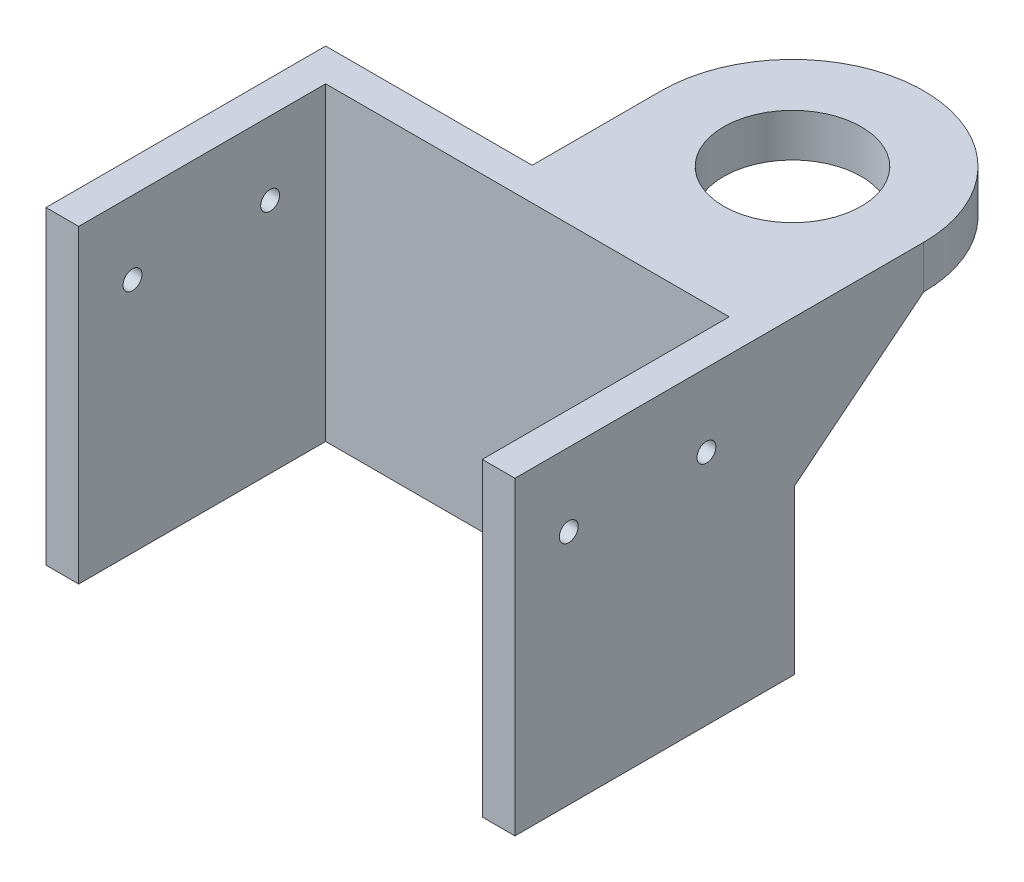
from build123d import *

# Parameters (mm, degrees)
SKETCH_1_W          = 54.5
SKETCH_1_H          = 32.5
EXTRUDE_2_DEPTH     = 34
EXTRUDE_3_DEPTH     = 5
EXTRUDE_6_DEPTH     = 4
SKETCH_14_W         = 46.9
SKETCH_14_H         = 28.7
CUT_EXTRUDE_6_DEPTH = 35
SKETCH_15_R         = 1.1
CUT_EXTRUDE_7_DEPTH = 47
EXTRUDE_7_DEPTH     = 2
SKETCH_18_R         = 8
CUT_EXTRUDE_8_DEPTH = 10
SKETCH_19_R         = 1
CUT_EXTRUDE_9_DEPTH = 20


with BuildPart() as part:
    # 草图1 → 凸台-拉伸2 (new body)
    with BuildSketch(Plane(origin=(0, 0, 0), x_dir=(1, 0, 0), z_dir=(0, 1, 0))):
        with Locations((4.534184514, 3.63509061)):
            Rectangle(SKETCH_1_W, SKETCH_1_H)
    extrude(amount=EXTRUDE_2_DEPTH)

    # 草图3 → 凸台-拉伸3 (add)
    with BuildSketch(Plane(origin=(0, 34, 0), x_dir=(1, 0, 0), z_dir=(0, 1, 0))):
        with BuildLine():
            Line((1.284184514, 34.88509061), (1.284184514, 19.88509061))
            Line((1.284184514, 19.88509061), (31.784184514, 19.88509061))
            Line((31.784184514, 19.88509061), (31.784184514, 34.88509061))
            ThreePointArc((31.784184514, 34.88509061), (16.534184514, 50.13509061), (1.284184514, 34.88509061))
        make_face()
    extrude_3 = extrude(amount=-EXTRUDE_3_DEPTH)

    # 草图11 → 凸台-拉伸6 (add)
    with BuildSketch(Plane.ZY.offset(-1.284184514)):
        Polygon((-34.88509061, 29), (-19.88509061, 17), (-19.88509061, 29), align=None)
    extrude_6 = extrude(amount=-EXTRUDE_6_DEPTH)

    # 镜向1: 凸台-拉伸3, 凸台-拉伸6 across plane
    add(extrude_3.mirror(Plane.ZY.offset(-16.534184514)))
    add(extrude_6.mirror(Plane.ZY.offset(-16.534184514)))

    # 草图14 → 切除-拉伸6 (cut, through all)
    with BuildSketch(Plane(origin=(0, 34, 0), x_dir=(1, 0, 0), z_dir=(0, 1, 0))):
        with Locations((4.534184514, 1.73509061)):
            Rectangle(SKETCH_14_W, SKETCH_14_H)
    extrude(amount=-CUT_EXTRUDE_6_DEPTH, mode=Mode.SUBTRACT)

    # 草图15 → 切除-拉伸7 (cut, symmetric)
    with BuildSketch(Plane.ZY.offset(-16.534184514)):
        with Locations((-9.63509061, 25.5)):
            Circle(SKETCH_15_R)
        with Locations((6.36490939, 25.5)):
            Circle(SKETCH_15_R)
    extrude(amount=CUT_EXTRUDE_7_DEPTH, both=True, mode=Mode.SUBTRACT)

    # 草图17 → 凸台-拉伸7 (add)
    with BuildSketch(Plane(origin=(0, 0, 0), x_dir=(1, 0, 0), z_dir=(0, 1, 0))):
        Polygon((-22.715815486, -12.61490939), (-22.715815486, 19.88509061), (31.784184514, 19.88509061), (31.784184514, -12.61490939), (27.984184514, -12.61490939), (27.984184514, 16.08509061), (-18.915815486, 16.08509061), (-18.915815486, -12.61490939), align=None)
    extrude(amount=-EXTRUDE_7_DEPTH)

    # 草图18 → 切除-拉伸8 (cut)
    with BuildSketch(Plane(origin=(0, 34, 0), x_dir=(1, 0, 0), z_dir=(0, 1, 0))):
        with Locations((16.534184514, 34.88509061)):
            Circle(SKETCH_18_R)
    extrude(amount=-CUT_EXTRUDE_8_DEPTH, mode=Mode.SUBTRACT)

    # 草图19 → 切除-拉伸9 (cut)
    with BuildSketch(Plane.XZ.offset(2)):
        with Locations((29.784184514, -17.88509061)):
            Circle(SKETCH_19_R)
        with Locations((-20.715815486, -17.88509061)):
            Circle(SKETCH_19_R)
    extrude(amount=-CUT_EXTRUDE_9_DEPTH, mode=Mode.SUBTRACT)


solid = part.part
